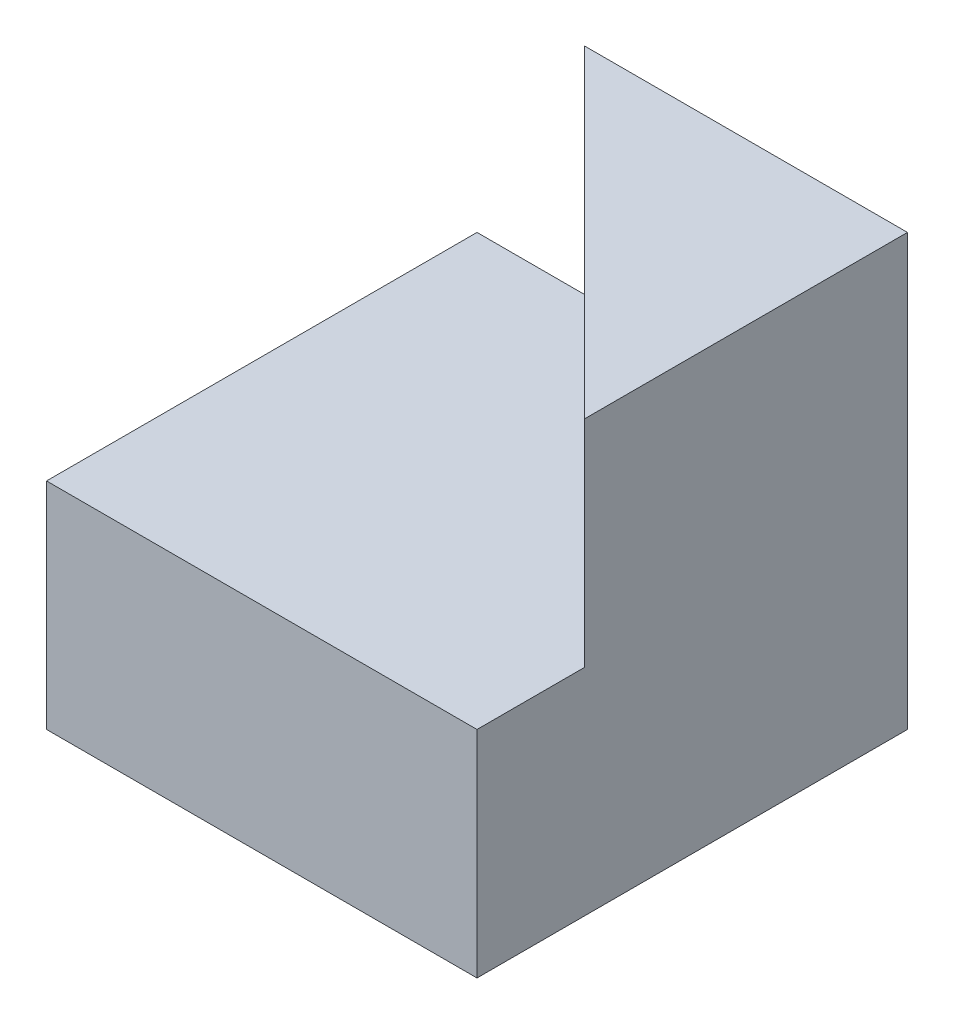
from build123d import *

# Parameters (mm, degrees)
SKETCH1_W           = 40
SKETCH1_H           = 40
BOSS_EXTRUDE1_DEPTH = 40
SKETCH2_W           = 10
SKETCH2_H           = 20
CUT_EXTRUDE1_DEPTH  = 40
CUT_EXTRUDE3_DEPTH  = 20


with BuildPart() as part:
    # Sketch1 → Boss-Extrude1 (new body)
    with BuildSketch(Plane.XY):
        with Locations((20, 20)):
            Rectangle(SKETCH1_W, SKETCH1_H)
    extrude(amount=BOSS_EXTRUDE1_DEPTH)

    # Sketch2 → Cut-Extrude1 (cut)
    with BuildSketch(Plane.XY.offset(40)):
        with Locations((5, 30)):
            Rectangle(SKETCH2_W, SKETCH2_H)
    extrude(amount=-CUT_EXTRUDE1_DEPTH, mode=Mode.SUBTRACT)

    # Sketch3 → Cut-Extrude3 (cut)
    with BuildSketch(Plane(origin=(0, 40, 0), x_dir=(1, 0, 0), z_dir=(0, 1, 0))):
        Polygon((40, -30), (10, 0), (10, -40), (40, -40), align=None)
    extrude(amount=-CUT_EXTRUDE3_DEPTH, mode=Mode.SUBTRACT)


solid = part.part
